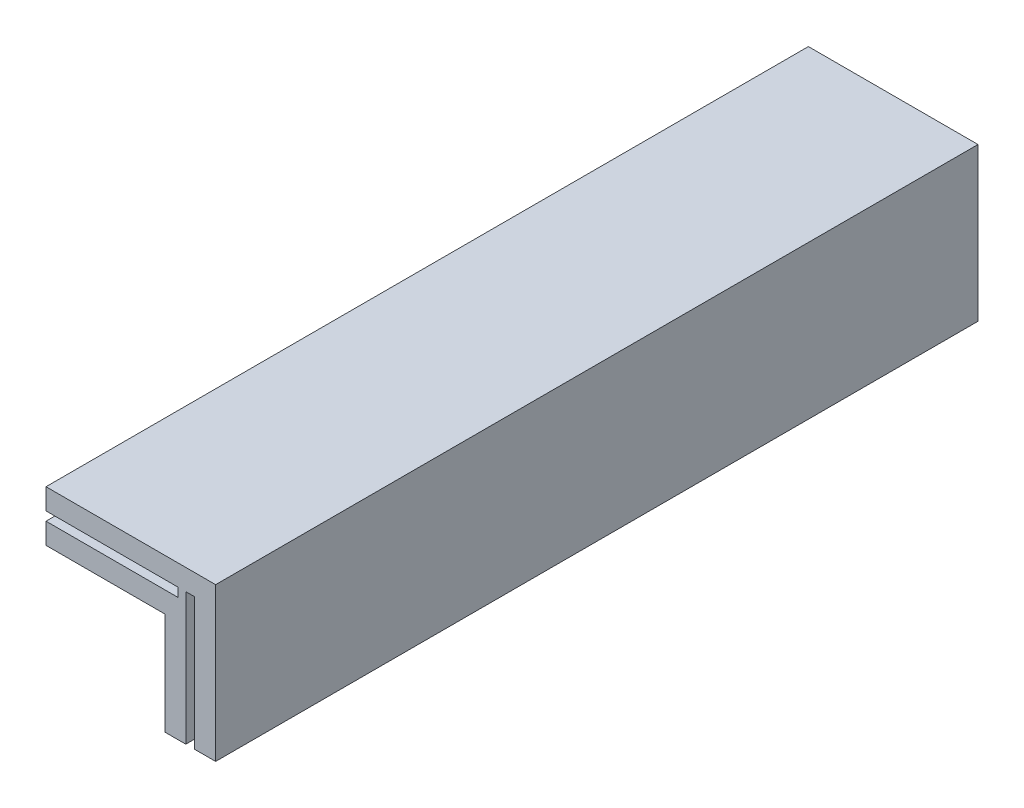
from build123d import *

# Parameters (mm, degrees)
SKETCH1_W           = 4.675
SKETCH1_H           = 0.825
BOSS_EXTRUDE1_DEPTH = 30


with BuildPart() as part:
    # Sketch1 → Boss-Extrude1 (new body)
    with BuildSketch(Plane.XY):
        with Locations((-3.3375, 1.6125)):
            Rectangle(SKETCH1_W, SKETCH1_H)
        with Locations((-3.3375, 0.4375)):
            Rectangle(SKETCH1_W, SKETCH1_H)
        Polygon((1, 2.025), (-1, 2.025), (-1, 1.2), (-0.475, 1.2), (-0.475, 0.85), (-1, 0.85), (-1, 0.025), (-1, -4), (-0.175, -4), (-0.175, 1.2), (0.175, 1.2), (0.175, -4), (1, -4), align=None)
    extrude(amount=BOSS_EXTRUDE1_DEPTH)


solid = part.part
